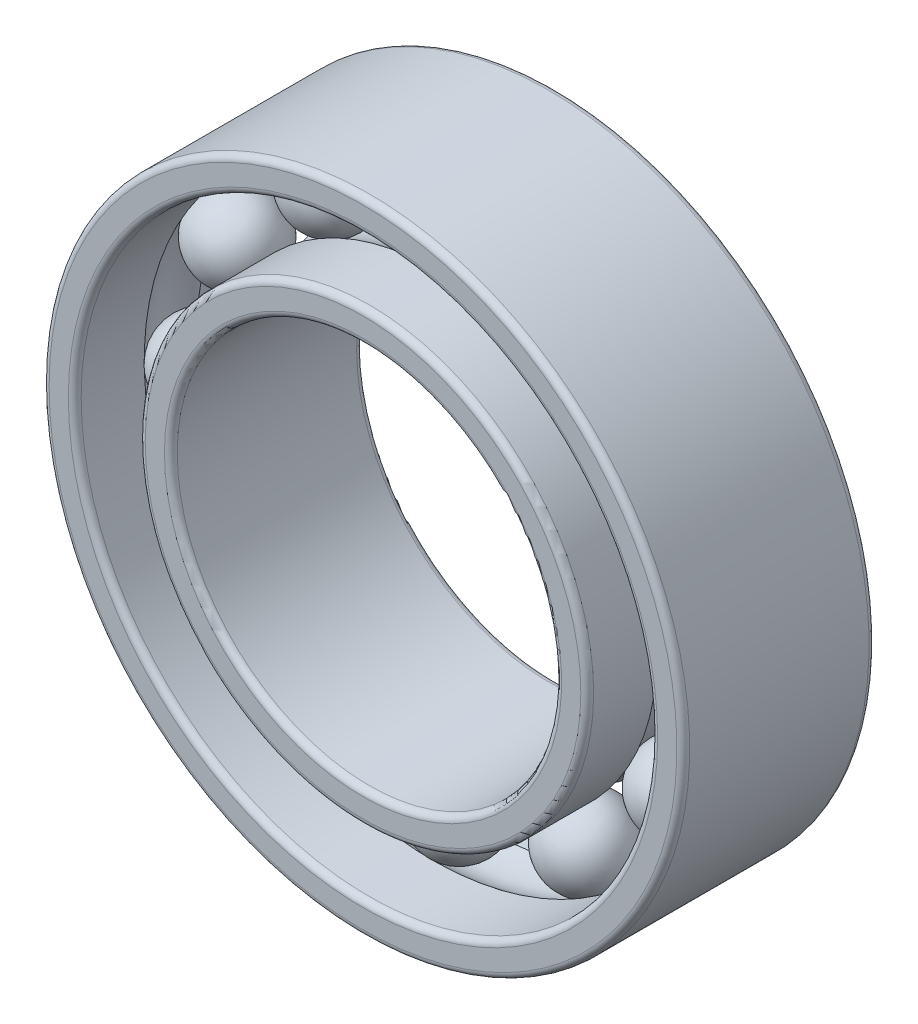
from build123d import *

# Parameters (mm, degrees)
KREISMUSTER4_COUNT = 12
VERRUNDUNG1_R      = 0.1
VERRUNDUNG2_R      = 0.1


with BuildPart() as part:
    # Skizze1 → Rotation1 (revolve)
    with BuildSketch(Plane(origin=(0, 0, 0), x_dir=(0, 0, -1), z_dir=(1, 0, 0))):
        with BuildLine():
            Line((1.5, 5), (-1.5, 5))
            Line((-1.5, 5), (-1.5, 4.5))
            Line((-1.5, 4.5), (-0.415331193, 4.5))
            ThreePointArc((-0.415331193, 4.5), (0, 4.65), (0.415331193, 4.5))
            Line((0.415331193, 4.5), (1.5, 4.5))
            Line((1.5, 4.5), (1.5, 5))
        make_face()
        with BuildLine():
            ThreePointArc((0.415331193, 3.5), (0, 3.35), (-0.415331193, 3.5))
            Line((-0.415331193, 3.5), (-1.5, 3.5))
            Line((-1.5, 3.5), (-1.5, 3))
            Line((-1.5, 3), (1.5, 3))
            Line((1.5, 3), (1.5, 3.5))
            Line((1.5, 3.5), (0.415331193, 3.5))
        make_face()
    revolve(axis=Axis((0, 0, 0), (0, 0, -1)))

    # Verrundung1
    verrundung1_edges = [part.edges().sort_by_distance(p)[0] for p in [
        (0, -4.5, -1.5),
        (0, -4.5, 1.5),
        (0, -5, -1.5),
        (0, -5, 1.5),
    ]]
    fillet(verrundung1_edges, radius=VERRUNDUNG1_R)

    # Verrundung2
    verrundung2_edges = [part.edges().sort_by_distance(p)[0] for p in [
        (0, -3.5, -1.5),
        (0, -3, -1.5),
        (0, -3.5, 1.5),
        (0, -3, 1.5),
    ]]
    fillet(verrundung2_edges, radius=VERRUNDUNG2_R)


with BuildPart() as body_2:
    # Skizze1_5 → Rotation3 (revolve)
    with BuildSketch(Plane(origin=(0, 0, 0), x_dir=(0, 0, -1), z_dir=(1, 0, 0))):
        with BuildLine():
            ThreePointArc((0.415331193, 4.5), (0, 4.65), (-0.415331193, 4.5))
            ThreePointArc((-0.415331193, 4.5), (-0.588415362, 4.276165462), (-0.65, 4))
            Line((-0.65, 4), (0.65, 4))
            ThreePointArc((0.65, 4), (0.588415362, 4.276165462), (0.415331193, 4.5))
        make_face()
    revolve(axis=Axis((0, 4, 0.65), (0, 0, -1)))


with BuildPart() as kreismuster4_1:
    # Kreismuster4: pattern copy
    add(body_2.part.rotate(Axis((0, 0, -1.5), (0, 0, 1)), 1 * 360 / KREISMUSTER4_COUNT))


with BuildPart() as kreismuster4_2:
    # Kreismuster4: pattern copy
    add(body_2.part.rotate(Axis((0, 0, -1.5), (0, 0, 1)), 2 * 360 / KREISMUSTER4_COUNT))


with BuildPart() as kreismuster4_3:
    # Kreismuster4: pattern copy
    add(body_2.part.rotate(Axis((0, 0, -1.5), (0, 0, 1)), 3 * 360 / KREISMUSTER4_COUNT))


with BuildPart() as kreismuster4_4:
    # Kreismuster4: pattern copy
    add(body_2.part.rotate(Axis((0, 0, -1.5), (0, 0, 1)), 4 * 360 / KREISMUSTER4_COUNT))


with BuildPart() as kreismuster4_5:
    # Kreismuster4: pattern copy
    add(body_2.part.rotate(Axis((0, 0, -1.5), (0, 0, 1)), 5 * 360 / KREISMUSTER4_COUNT))


with BuildPart() as kreismuster4_6:
    # Kreismuster4: pattern copy
    add(body_2.part.rotate(Axis((0, 0, -1.5), (0, 0, 1)), 6 * 360 / KREISMUSTER4_COUNT))


with BuildPart() as kreismuster4_7:
    # Kreismuster4: pattern copy
    add(body_2.part.rotate(Axis((0, 0, -1.5), (0, 0, 1)), 7 * 360 / KREISMUSTER4_COUNT))


with BuildPart() as kreismuster4_8:
    # Kreismuster4: pattern copy
    add(body_2.part.rotate(Axis((0, 0, -1.5), (0, 0, 1)), 8 * 360 / KREISMUSTER4_COUNT))


with BuildPart() as kreismuster4_9:
    # Kreismuster4: pattern copy
    add(body_2.part.rotate(Axis((0, 0, -1.5), (0, 0, 1)), 9 * 360 / KREISMUSTER4_COUNT))


with BuildPart() as kreismuster4_10:
    # Kreismuster4: pattern copy
    add(body_2.part.rotate(Axis((0, 0, -1.5), (0, 0, 1)), 10 * 360 / KREISMUSTER4_COUNT))


with BuildPart() as kreismuster4_11:
    # Kreismuster4: pattern copy
    add(body_2.part.rotate(Axis((0, 0, -1.5), (0, 0, 1)), 11 * 360 / KREISMUSTER4_COUNT))


solid = Compound([part.part, body_2.part, kreismuster4_1.part, kreismuster4_2.part, kreismuster4_3.part, kreismuster4_4.part, kreismuster4_5.part, kreismuster4_6.part, kreismuster4_7.part, kreismuster4_8.part, kreismuster4_9.part, kreismuster4_10.part, kreismuster4_11.part])
